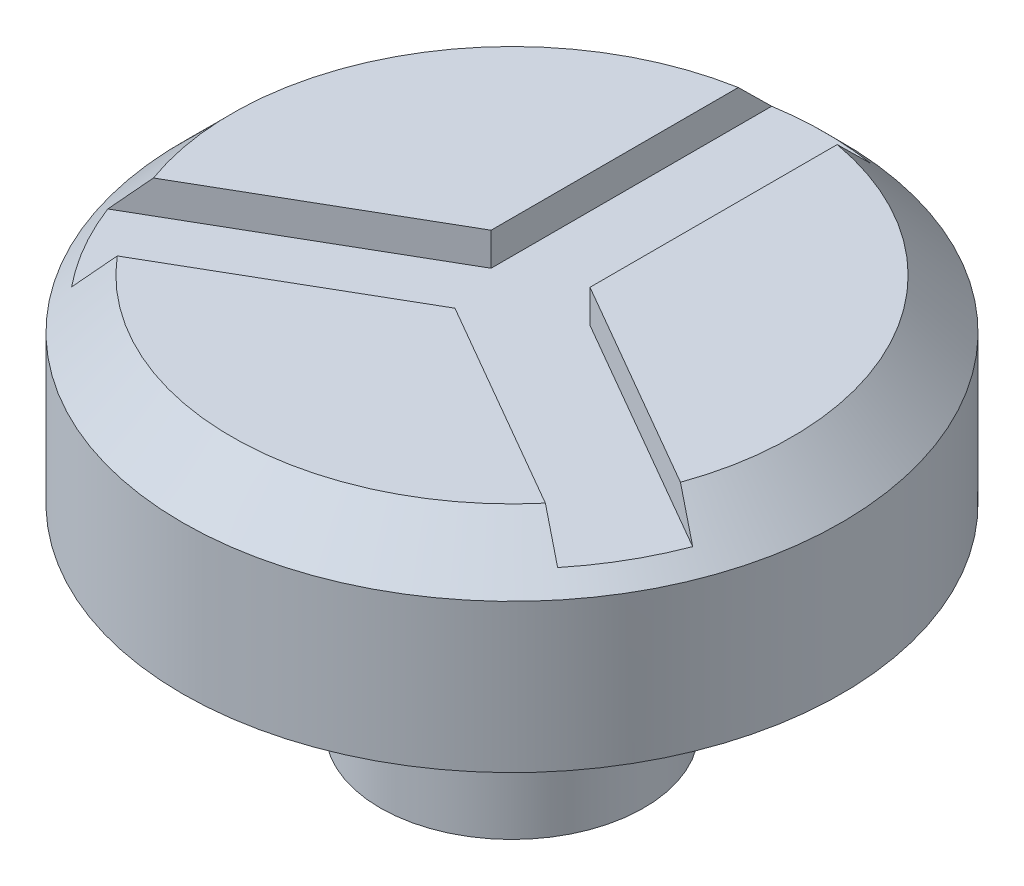
from build123d import *

# Parameters (mm, degrees)
SKETCH1_R           = 20
BOSS_EXTRUDE1_DEPTH = 30
SKETCH2_R           = 50
BOSS_EXTRUDE2_DEPTH = 30
CHAMFER1_SIZE       = 7.5
CUT_EXTRUDE1_DEPTH  = 5


with BuildPart() as part:
    # Sketch1 → Boss-Extrude1 (new body)
    with BuildSketch(Plane(origin=(0, 0, 0), x_dir=(1, 0, 0), z_dir=(0, 1, 0))):
        Circle(SKETCH1_R)
    extrude(amount=BOSS_EXTRUDE1_DEPTH)

    # Sketch2 → Boss-Extrude2 (add)
    with BuildSketch(Plane(origin=(0, 30, 0), x_dir=(1, 0, 0), z_dir=(0, 1, 0))):
        Circle(SKETCH2_R)
    extrude(amount=BOSS_EXTRUDE2_DEPTH)

    # Chamfer1
    chamfer1_edges = [part.edges().sort_by_distance(p)[0] for p in [
        (-50, 60, 0),
    ]]
    chamfer(chamfer1_edges, length=CHAMFER1_SIZE)

    # Sketch3 → Cut-Extrude1 (cut)
    with BuildSketch(Plane(origin=(0, 60, 0), x_dir=(1, 0, 0), z_dir=(0, 1, 0))):
        with BuildLine():
            Line((47.051270189, -18.504809472), (7.5, 4.330127019))
            Line((7.5, 4.330127019), (7.5, 50))
            ThreePointArc((7.5, 50), (0, 57.5), (-7.5, 50))
            Line((-7.5, 50), (-7.5, 4.330127019))
            Line((-7.5, 4.330127019), (-47.051270189, -18.504809472))
            ThreePointArc((-47.051270189, -18.504809472), (-49.796460718, -28.75), (-39.551270189, -31.495190528))
            Line((-39.551270189, -31.495190528), (0, -8.660254038))
            Line((0, -8.660254038), (39.551270189, -31.495190528))
            ThreePointArc((39.551270189, -31.495190528), (49.796460718, -28.75), (47.051270189, -18.504809472))
        make_face()
    extrude(amount=-CUT_EXTRUDE1_DEPTH, mode=Mode.SUBTRACT)


solid = part.part
